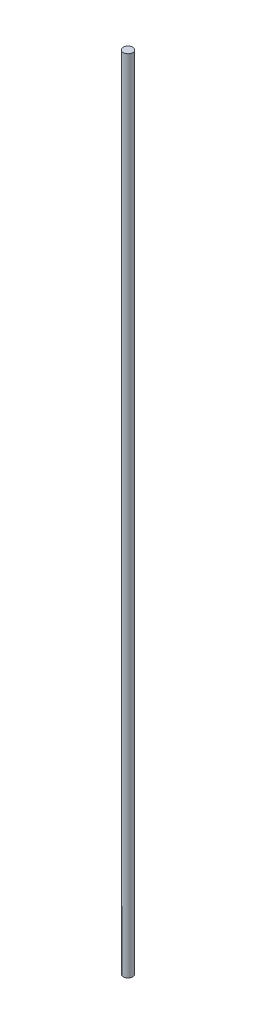
from build123d import *

# Parameters (mm, degrees)
SKETCH1_R           = 2.5
BOSS_EXTRUDE1_DEPTH = 420


with BuildPart() as part:
    # Sketch1 → Boss-Extrude1 (new body)
    with BuildSketch(Plane(origin=(0, 0, 0), x_dir=(1, 0, 0), z_dir=(0, 1, 0))):
        Circle(SKETCH1_R)
    extrude(amount=BOSS_EXTRUDE1_DEPTH)


solid = part.part
